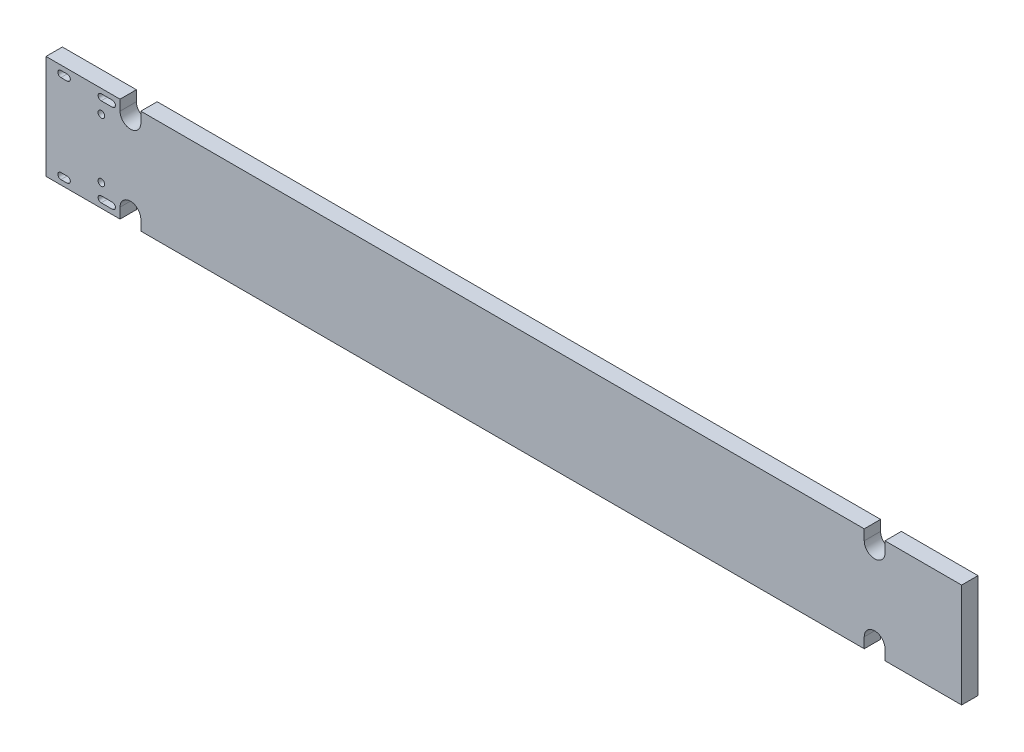
from build123d import *

# Parameters (mm, degrees)
SKETCH_2_R      = 0.325658607
EXTRUDE_1_DEPTH = 1.6


with BuildPart() as part:
    # 草图2 → 凸台-拉伸1 (new body)
    with BuildSketch(Plane.XY):
        with BuildLine():
            Line((1.524, 5.08), (1.524, -5.08))
            Line((1.524, -5.08), (8.763, -5.08))
            Line((8.763, -5.08), (8.763, -4.064))
            ThreePointArc((8.763, -4.064), (9.779, -3.048), (10.795, -4.064))
            Line((10.795, -4.064), (10.795, -5.08))
            Line((10.795, -5.08), (81.534, -5.08))
            Line((81.534, -5.08), (81.534, -4.064))
            ThreePointArc((81.534, -4.064), (82.55, -3.048), (83.566, -4.064))
            Line((83.566, -4.064), (83.566, -5.08))
            Line((83.566, -5.08), (91.059, -5.08))
            Line((91.059, -5.08), (91.059, 5.08))
            Line((91.059, 5.08), (83.566, 5.08))
            Line((83.566, 5.08), (83.566, 4.064))
            ThreePointArc((83.566, 4.064), (82.55, 3.048), (81.534, 4.064))
            Line((81.534, 4.064), (81.534, 5.08))
            Line((81.534, 5.08), (10.795, 5.08))
            Line((10.795, 5.08), (10.795, 4.064))
            ThreePointArc((10.795, 4.064), (9.779, 3.048), (8.763, 4.064))
            Line((8.763, 4.064), (8.763, 5.08))
            Line((8.763, 5.08), (1.524, 5.08))
        make_face()
        with Locations((6.937038713, 2.89)):
            Circle(SKETCH_2_R, mode=Mode.SUBTRACT)
        with Locations((6.937038713, -2.89)):
            Circle(SKETCH_2_R, mode=Mode.SUBTRACT)
        with BuildLine():
            Line((2.982, 4.62), (3.602, 4.62))
            ThreePointArc((3.602, 4.62), (3.902, 4.32), (3.602, 4.02))
            Line((3.602, 4.02), (2.982, 4.02))
            ThreePointArc((2.982, 4.02), (2.682, 4.32), (2.982, 4.62))
        make_face(mode=Mode.SUBTRACT)
        with BuildLine():
            Line((6.917, 4.62), (8.017, 4.62))
            ThreePointArc((8.017, 4.62), (8.317, 4.32), (8.017, 4.02))
            Line((8.017, 4.02), (6.917, 4.02))
            ThreePointArc((6.917, 4.02), (6.617, 4.32), (6.917, 4.62))
        make_face(mode=Mode.SUBTRACT)
        with BuildLine():
            Line((8.017, -4.02), (6.917, -4.02))
            ThreePointArc((6.917, -4.02), (6.617, -4.32), (6.917, -4.62))
            Line((6.917, -4.62), (8.017, -4.62))
            ThreePointArc((8.017, -4.62), (8.317, -4.32), (8.017, -4.02))
        make_face(mode=Mode.SUBTRACT)
        with BuildLine():
            Line((3.602, -4.02), (2.982, -4.02))
            ThreePointArc((2.982, -4.02), (2.682, -4.32), (2.982, -4.62))
            Line((2.982, -4.62), (3.602, -4.62))
            ThreePointArc((3.602, -4.62), (3.902, -4.32), (3.602, -4.02))
        make_face(mode=Mode.SUBTRACT)
    extrude(amount=EXTRUDE_1_DEPTH)


solid = part.part
